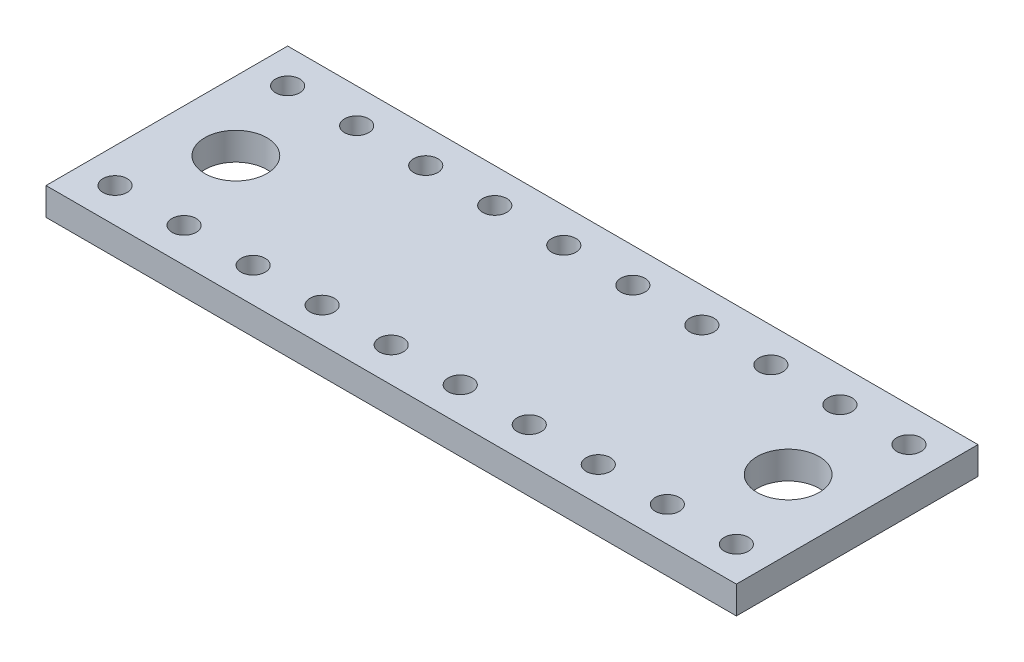
from build123d import *

# Parameters (mm, degrees)
SKETCH1_W                = 100
SKETCH1_H                = 35
BOSS_EXTRUDE1_DEPTH      = 4
SKETCH2_R                = 1.75
CUT_EXTRUDE1_DEPTH       = 107.023582282
LPATTERN1_COUNT          = 10
LPATTERN1_PITCH          = 10
MIRROR1_COPY_1_SKETCH_R  = 1.75
MIRROR1_COPY_1_DEPTH     = 107.023582282
MIRROR1_COPY_2_SKETCH_R  = 1.75
MIRROR1_COPY_2_DEPTH     = 107.023582282
MIRROR1_COPY_3_SKETCH_R  = 1.75
MIRROR1_COPY_3_DEPTH     = 107.023582282
MIRROR1_COPY_4_SKETCH_R  = 1.75
MIRROR1_COPY_4_DEPTH     = 107.023582282
MIRROR1_COPY_5_SKETCH_R  = 1.75
MIRROR1_COPY_5_DEPTH     = 107.023582282
MIRROR1_COPY_6_SKETCH_R  = 1.75
MIRROR1_COPY_6_DEPTH     = 107.023582282
MIRROR1_COPY_7_SKETCH_R  = 1.75
MIRROR1_COPY_7_DEPTH     = 107.023582282
MIRROR1_COPY_8_SKETCH_R  = 1.75
MIRROR1_COPY_8_DEPTH     = 107.023582282
MIRROR1_COPY_9_SKETCH_R  = 1.75
MIRROR1_COPY_9_DEPTH     = 107.023582282
MIRROR1_COPY_10_SKETCH_R = 1.75
MIRROR1_COPY_10_DEPTH    = 107.023582282
SKETCH2_3_R              = 4.5
CUT_EXTRUDE3_DEPTH       = 4


with BuildPart() as part:
    # Sketch1 → Boss-Extrude1 (new body)
    with BuildSketch(Plane(origin=(0, 0, 0), x_dir=(1, 0, 0), z_dir=(0, 1, 0))):
        with Locations((50, 17.5)):
            Rectangle(SKETCH1_W, SKETCH1_H)
    extrude(amount=BOSS_EXTRUDE1_DEPTH)

    # Sketch2 → Cut-Extrude1 (cut, symmetric)
    with BuildSketch(Plane(origin=(0, 4, 0), x_dir=(1, 0, 0), z_dir=(0, 1, 0))):
        with Locations((5, 30)):
            Circle(SKETCH2_R)
    cut_extrude1 = extrude(amount=CUT_EXTRUDE1_DEPTH, both=True, mode=Mode.SUBTRACT)

    # LPattern1: Cut-Extrude1 ×10
    with Locations(*[(i * LPATTERN1_PITCH, 0, 0) for i in range(1, LPATTERN1_COUNT)]):
        add(cut_extrude1, mode=Mode.SUBTRACT)

    # Mirror1 copy 1 sketch → Mirror1 copy 1 (cut, symmetric)
    with BuildSketch(Plane(origin=(10, 4, -35), x_dir=(1, 0, 0), z_dir=(0, 1, 0))):
        with Locations((5, -30)):
            Circle(MIRROR1_COPY_1_SKETCH_R)
    extrude(amount=MIRROR1_COPY_1_DEPTH, both=True, mode=Mode.SUBTRACT)

    # Mirror1 copy 2 sketch → Mirror1 copy 2 (cut, symmetric)
    with BuildSketch(Plane(origin=(20, 4, -35), x_dir=(1, 0, 0), z_dir=(0, 1, 0))):
        with Locations((5, -30)):
            Circle(MIRROR1_COPY_2_SKETCH_R)
    extrude(amount=MIRROR1_COPY_2_DEPTH, both=True, mode=Mode.SUBTRACT)

    # Mirror1 copy 3 sketch → Mirror1 copy 3 (cut, symmetric)
    with BuildSketch(Plane(origin=(30, 4, -35), x_dir=(1, 0, 0), z_dir=(0, 1, 0))):
        with Locations((5, -30)):
            Circle(MIRROR1_COPY_3_SKETCH_R)
    extrude(amount=MIRROR1_COPY_3_DEPTH, both=True, mode=Mode.SUBTRACT)

    # Mirror1 copy 4 sketch → Mirror1 copy 4 (cut, symmetric)
    with BuildSketch(Plane(origin=(40, 4, -35), x_dir=(1, 0, 0), z_dir=(0, 1, 0))):
        with Locations((5, -30)):
            Circle(MIRROR1_COPY_4_SKETCH_R)
    extrude(amount=MIRROR1_COPY_4_DEPTH, both=True, mode=Mode.SUBTRACT)

    # Mirror1 copy 5 sketch → Mirror1 copy 5 (cut, symmetric)
    with BuildSketch(Plane(origin=(50, 4, -35), x_dir=(1, 0, 0), z_dir=(0, 1, 0))):
        with Locations((5, -30)):
            Circle(MIRROR1_COPY_5_SKETCH_R)
    extrude(amount=MIRROR1_COPY_5_DEPTH, both=True, mode=Mode.SUBTRACT)

    # Mirror1 copy 6 sketch → Mirror1 copy 6 (cut, symmetric)
    with BuildSketch(Plane(origin=(60, 4, -35), x_dir=(1, 0, 0), z_dir=(0, 1, 0))):
        with Locations((5, -30)):
            Circle(MIRROR1_COPY_6_SKETCH_R)
    extrude(amount=MIRROR1_COPY_6_DEPTH, both=True, mode=Mode.SUBTRACT)

    # Mirror1 copy 7 sketch → Mirror1 copy 7 (cut, symmetric)
    with BuildSketch(Plane(origin=(70, 4, -35), x_dir=(1, 0, 0), z_dir=(0, 1, 0))):
        with Locations((5, -30)):
            Circle(MIRROR1_COPY_7_SKETCH_R)
    extrude(amount=MIRROR1_COPY_7_DEPTH, both=True, mode=Mode.SUBTRACT)

    # Mirror1 copy 8 sketch → Mirror1 copy 8 (cut, symmetric)
    with BuildSketch(Plane(origin=(80, 4, -35), x_dir=(1, 0, 0), z_dir=(0, 1, 0))):
        with Locations((5, -30)):
            Circle(MIRROR1_COPY_8_SKETCH_R)
    extrude(amount=MIRROR1_COPY_8_DEPTH, both=True, mode=Mode.SUBTRACT)

    # Mirror1 copy 9 sketch → Mirror1 copy 9 (cut, symmetric)
    with BuildSketch(Plane(origin=(90, 4, -35), x_dir=(1, 0, 0), z_dir=(0, 1, 0))):
        with Locations((5, -30)):
            Circle(MIRROR1_COPY_9_SKETCH_R)
    extrude(amount=MIRROR1_COPY_9_DEPTH, both=True, mode=Mode.SUBTRACT)

    # Mirror1 copy 10 sketch → Mirror1 copy 10 (cut, symmetric)
    with BuildSketch(Plane(origin=(0, 4, -35), x_dir=(1, 0, 0), z_dir=(0, 1, 0))):
        with Locations((5, -30)):
            Circle(MIRROR1_COPY_10_SKETCH_R)
    extrude(amount=MIRROR1_COPY_10_DEPTH, both=True, mode=Mode.SUBTRACT)

    # Sketch2_3 → Cut-Extrude3 (cut)
    with BuildSketch(Plane(origin=(0, 4, 0), x_dir=(1, 0, 0), z_dir=(0, 1, 0))):
        with Locations((10, 17.5)):
            Circle(SKETCH2_3_R)
    cut_extrude3 = extrude(amount=-CUT_EXTRUDE3_DEPTH, mode=Mode.SUBTRACT)

    # Mirror2: Cut-Extrude3 across plane
    add(cut_extrude3.mirror(Plane(origin=(50, 0, 0), x_dir=(0, 0, 1), z_dir=(1, 0, 0))), mode=Mode.SUBTRACT)


solid = part.part
